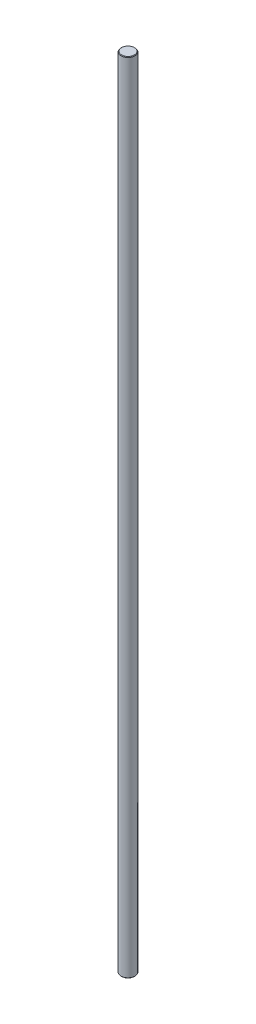
from build123d import *

# Parameters (mm, degrees)
SKETCH1_R           = 2.5
BOSS_EXTRUDE1_DEPTH = 287
CHAMFER1_SIZE       = 0.2


with BuildPart() as part:
    # Sketch1 → Boss-Extrude1 (new body)
    with BuildSketch(Plane(origin=(0, 0, 0), x_dir=(1, 0, 0), z_dir=(0, 1, 0))):
        Circle(SKETCH1_R)
    extrude(amount=BOSS_EXTRUDE1_DEPTH)

    # Chamfer1
    chamfer1_edges = [part.edges().sort_by_distance(p)[0] for p in [
        (-2.5, 0, 0),
        (-2.5, 287, 0),
    ]]
    chamfer(chamfer1_edges, length=CHAMFER1_SIZE)


solid = part.part
